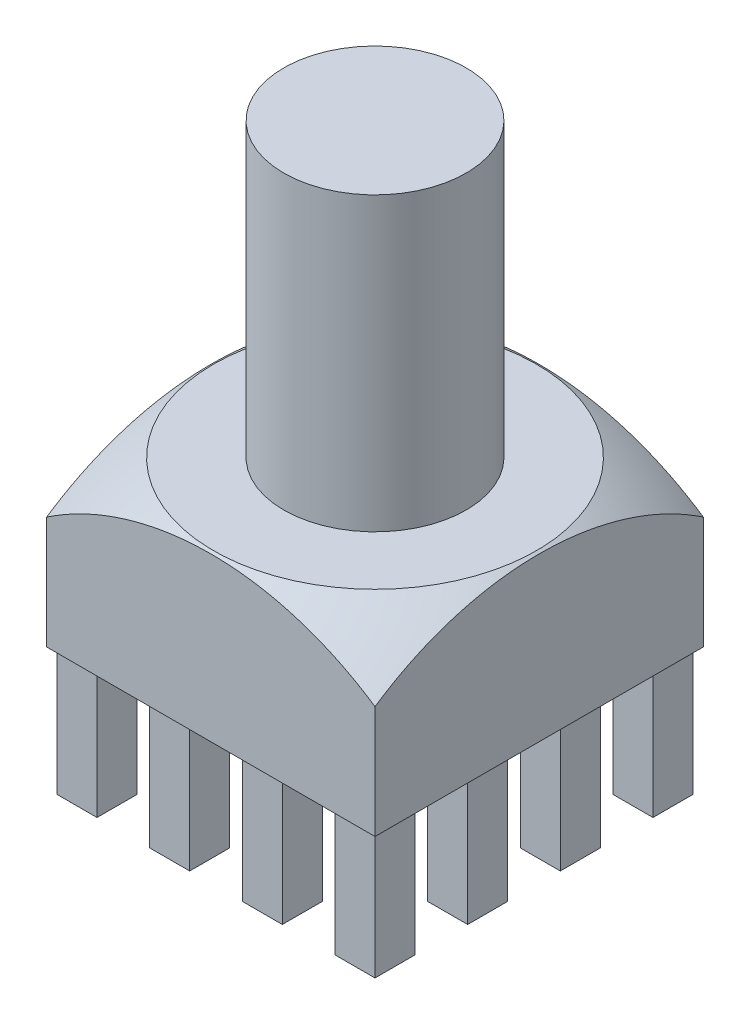
from build123d import *

# Parameters (mm, degrees)
SKETCH1_W            = 9
SKETCH1_H            = 9
BOSS_EXTRUDE1_DEPTH  = 4.5
SKETCH3_W            = 1.096908344
SKETCH3_H            = 1.096908344
BOSS_EXTRUDE3_DEPTH  = 3.5
LPATTERN1_COUNT      = 4
LPATTERN1_PITCH      = 2.54
LPATTERN1_COUNT_DIR2 = 4
LPATTERN1_PITCH_DIR2 = 2.54
SKETCH4_R            = 2.5
BOSS_EXTRUDE4_DEPTH  = 8


with BuildPart() as part:
    # Sketch1 → Boss-Extrude1 (new body)
    with BuildSketch(Plane(origin=(0, 0, 0), x_dir=(1, 0, 0), z_dir=(0, 1, 0))):
        Rectangle(SKETCH1_W, SKETCH1_H)
    extrude(amount=BOSS_EXTRUDE1_DEPTH)

    # Sketch3 → Boss-Extrude3 (add)
    with BuildSketch(Plane.XZ):
        with Locations((-3.81, 3.81)):
            Rectangle(SKETCH3_W, SKETCH3_H)
    boss_extrude3 = extrude(amount=BOSS_EXTRUDE3_DEPTH)

    # LPattern1: Boss-Extrude3 4 × 4
    with Locations(*[(i * LPATTERN1_PITCH, 0, -j * LPATTERN1_PITCH_DIR2) for i in range(LPATTERN1_COUNT) for j in range(LPATTERN1_COUNT_DIR2) if (i, j) != (0, 0)]):
        add(boss_extrude3)

    # Sketch4 → Boss-Extrude4 (add)
    with BuildSketch(Plane(origin=(0, 4.5, 0), x_dir=(1, 0, 0), z_dir=(0, 1, 0))):
        Circle(SKETCH4_R)
    extrude(amount=BOSS_EXTRUDE4_DEPTH)

    # Sketch6 → Cut-Revolve2 (revolve, cut)
    with BuildSketch(Plane(origin=(0, 0, 0), x_dir=(-0.707106781, 0, -0.707106781), z_dir=(0.707106781, 0, -0.707106781))):
        with BuildLine():
            Line((-8.778012628, -0.773952942), (-8.778012628, 5.788941631))
            Line((-8.778012628, 5.788941631), (-4.42783745, 5.788941631))
            Line((-4.42783745, 5.788941631), (-4.42783745, 4.5))
            ThreePointArc((-4.42783745, 4.5), (-7.110011532, 2.281289505), (-8.778012628, -0.773952942))
        make_face()
    revolve(axis=Axis((0, 4.5, 0), (0, -1, 0)), mode=Mode.SUBTRACT)


solid = part.part
